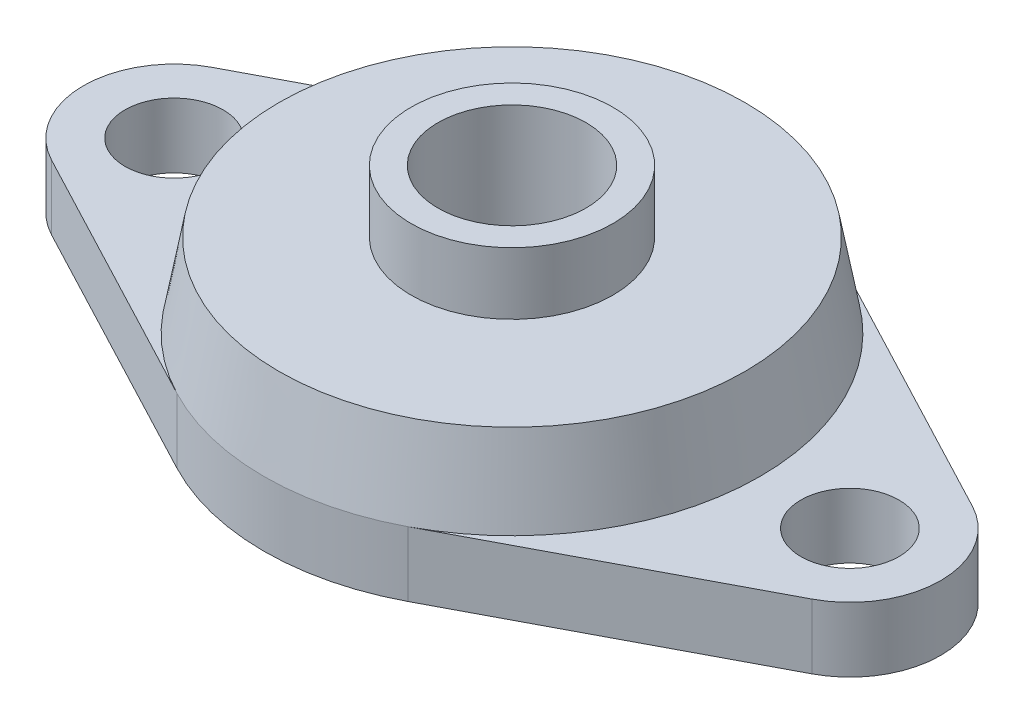
from build123d import *

# Parameters (mm, degrees)
BOSS_EXTRUDE1_DEPTH  = 3.5
SKETCH3_R            = 4
CUT_EXTRUDE1_DEPTH   = 30.056926885
M5_CLEARANCE_HOLE1_D = 5.3


with BuildPart() as part:
    # Sketch1 → Boss-Extrude1 (new body)
    with BuildSketch(Plane(origin=(0, 0, 0), x_dir=(1, 0, 0), z_dir=(0, 1, 0))):
        with BuildLine():
            Line((-23.15, 0), (0, 0))
            Line((0, 0), (0, 13.4))
            ThreePointArc((0, 13.4), (-3.214400781, 13.008751962), (-6.24109589, 11.857854869))
            Line((-6.24109589, 11.857854869), (-20.532191781, 4.336081258))
            ThreePointArc((-20.532191781, 4.336081258), (-22.44480272, 2.532514588), (-23.15, 0))
        make_face()
    extrude(amount=BOSS_EXTRUDE1_DEPTH)

    # Mirror3: part across plane


with BuildPart() as part_1:
    add(part.part)
    add(part.part.mirror(Plane(origin=(0, 3.5, 0), x_dir=(0, 0, 1), z_dir=(-1, 0, 0))))

    # Mirror4: part across plane


with BuildPart() as part_2:
    add(part_1.part)
    add(part_1.part.mirror(Plane(origin=(-23.15, 3.5, 0), x_dir=(1, 0, 0), z_dir=(0, 0, -1))))

    # Sketch2 → Revolve1 (revolve)
    with BuildSketch(Plane.XY):
        Polygon((0, 0), (0, 11.35), (5.44999985, 11.35), (5.44999985, 7.99999976), (12.582539385, 7.99999976), (13.4, 3.5), (13.4, 0), align=None)
    revolve(axis=Axis((0, 0, 0), (0, 1, 0)))

    # Sketch3 → Cut-Extrude1 (cut, through all)
    with BuildSketch(Plane.XZ):
        Circle(SKETCH3_R)
    extrude(amount=-CUT_EXTRUDE1_DEPTH, mode=Mode.SUBTRACT)

    # M5 Clearance Hole1 (through all)
    with Locations(Plane(origin=(0, 0, 0), x_dir=(-1, 0, 0), z_dir=(0, -1, 0))):
        with Locations((18.25, 0), (-18.25, 0)):
            Hole(M5_CLEARANCE_HOLE1_D / 2)


solid = part_2.part
